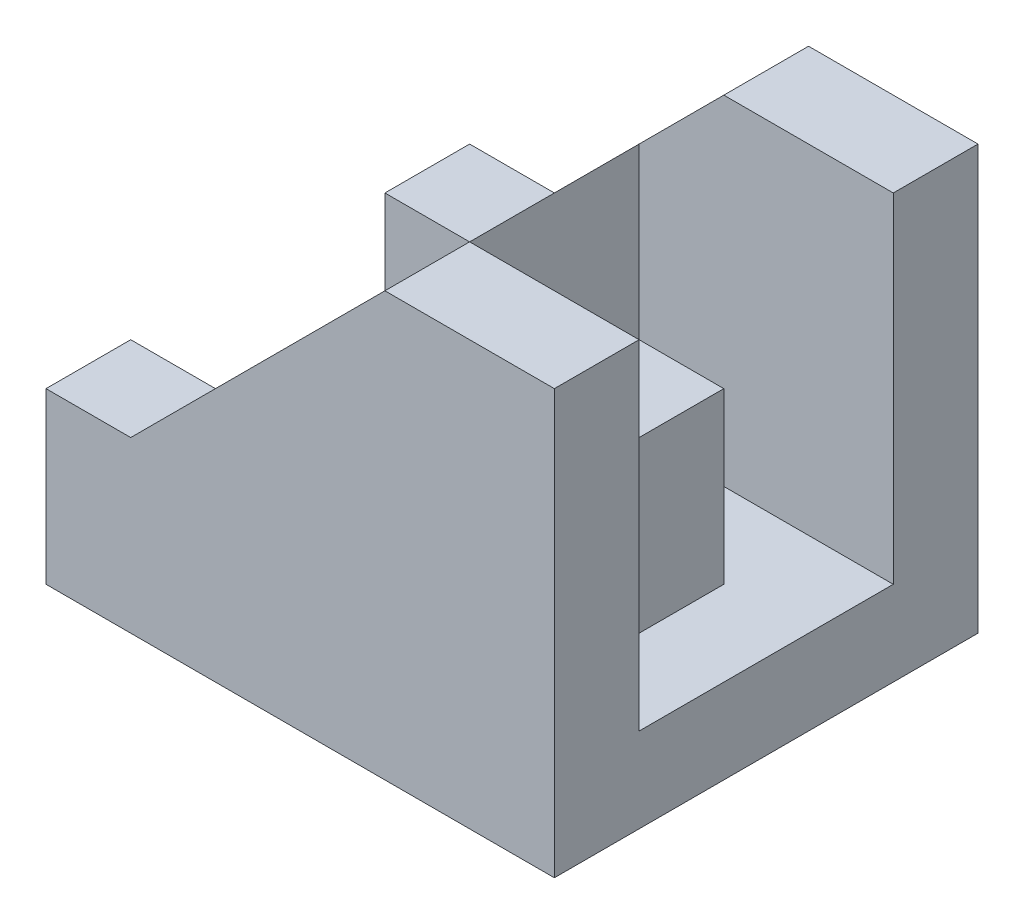
from build123d import *

# Parameters (mm, degrees)
BOSS_EXTRUDE1_DEPTH = 25
SKETCH2_W           = 5
SKETCH2_H           = 15
CUT_EXTRUDE1_DEPTH  = 25
SKETCH3_W           = 5
SKETCH3_H           = 5
CUT_EXTRUDE2_DEPTH  = 20
SKETCH4_W           = 5
SKETCH4_H           = 10
CUT_EXTRUDE3_DEPTH  = 10


with BuildPart() as part:
    # Sketch1 → Boss-Extrude1 (new body)
    with BuildSketch(Plane.XY):
        Polygon((0, 0), (30, 0), (30, 25), (20, 25), (5, 10), (0, 10), align=None)
    extrude(amount=BOSS_EXTRUDE1_DEPTH)

    # Sketch2 → Cut-Extrude1 (cut)
    with BuildSketch(Plane(origin=(0, 10, 0), x_dir=(1, 0, 0), z_dir=(0, 1, 0))):
        with Locations((2.5, -12.5)):
            Rectangle(SKETCH2_W, SKETCH2_H)
    extrude(amount=-CUT_EXTRUDE1_DEPTH, mode=Mode.SUBTRACT)

    # Sketch3 → Cut-Extrude2 (cut)
    with BuildSketch(Plane(origin=(0, 25, 0), x_dir=(1, 0, 0), z_dir=(0, 1, 0))):
        Polygon((30, -20), (30, -5), (20, -5), (20, -10), (25, -10), (25, -15), (20, -15), (20, -20), align=None)
        with Locations((17.5, -7.5)):
            Rectangle(SKETCH3_W, SKETCH3_H)
        with Locations((17.5, -17.5)):
            Rectangle(SKETCH3_W, SKETCH3_H)
    extrude(amount=-CUT_EXTRUDE2_DEPTH, mode=Mode.SUBTRACT)

    # Sketch4 → Cut-Extrude3 (cut)
    with BuildSketch(Plane(origin=(25, 0, 0), x_dir=(0, 0, -1), z_dir=(1, 0, 0))):
        with Locations((-12.5, 20)):
            Rectangle(SKETCH4_W, SKETCH4_H)
    extrude(amount=-CUT_EXTRUDE3_DEPTH, mode=Mode.SUBTRACT)


solid = part.part
